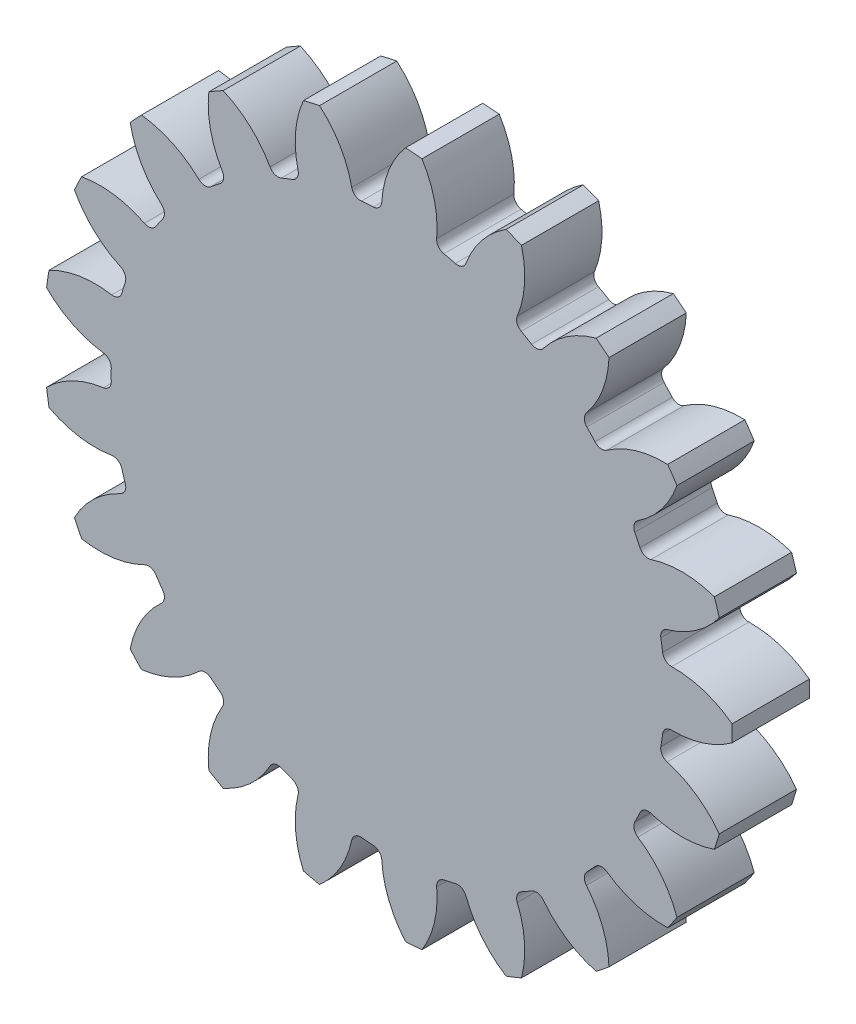
from build123d import *

# Parameters (mm, degrees)
SKETCH1_R                = 35.65
BOSS_EXTRUDE1_DEPTH      = 4
CUT_EXTRUDE1_DEPTH       = 5
FILLET1_R                = 0.93
CIRPATTERN1_COUNT        = 21
FILLET1_OF_CIRPATTERN1_R = 0.93


with BuildPart() as part:
    # Sketch1 → Boss-Extrude1 (new body, symmetric)
    with BuildSketch(Plane.XY):
        Circle(SKETCH1_R)
    extrude(amount=BOSS_EXTRUDE1_DEPTH, both=True)

    # Sketch4 → Cut-Extrude1 (cut, symmetric)
    with BuildSketch(Plane.XY):
        with BuildLine():
            ThreePointArc((-36.242364653, -5.451009479), (-32.872441369, -2.636648824), (-28.63673557, -1.480878422))
            ThreePointArc((-28.63673557, -1.480878422), (-28.675, 0), (-28.63673557, 1.480878422))
            ThreePointArc((-28.63673557, 1.480878422), (-32.872441369, 2.636648824), (-36.242364653, 5.451009479))
            ThreePointArc((-36.242364653, 5.451009479), (-36.65, 0), (-36.242364653, -5.451009479))
        make_face()
    cut_extrude1 = extrude(amount=CUT_EXTRUDE1_DEPTH, both=True, mode=Mode.SUBTRACT)

    # Fillet1
    fillet1_edges = [part.edges().sort_by_distance(p)[0] for p in [
        (-28.63673557, -1.480878422, 0),
        (-28.63673557, 1.480878422, 0),
    ]]
    fillet(fillet1_edges, radius=FILLET1_R)

    # CirPattern1: Cut-Extrude1 ×21 about axis
    cirpattern1_axis = Axis((0, 0, 0), (0, 0, 1))
    for i in range(1, CIRPATTERN1_COUNT):
        add(cut_extrude1.rotate(cirpattern1_axis, i * 360 / CIRPATTERN1_COUNT), mode=Mode.SUBTRACT)

    # Fillet1 of CirPattern1
    fillet1_of_cirpattern1_edges = [part.edges().sort_by_distance(p)[0] for p in [
        (-26.927989179, -9.855913136, 0),
        (-27.800982335, -7.025738839, 0),
        (-22.826572779, -17.355206716, 0),
        (-24.494989816, -14.908088372, 0),
        (-16.696915214, -23.312414018, 0),
        (-19.012509958, -21.46578883, 0),
        (-9.08366346, -27.198211029, 0),
        (-11.840685156, -26.116159749, 0),
        (-0.663288343, -28.667327632, 0),
        (-3.616763515, -28.445995266, 0),
        (7.816022853, -27.589226371, 0),
        (4.928523436, -28.24827927, 0),
        (15.600846118, -24.059701274, 0),
        (13.035889451, -25.540579696, 0),
        (21.999465743, -18.392366134, 0),
        (19.984959482, -20.563487533, 0),
        (26.443336294, -11.09078855, 0),
        (25.15827816, -13.759239261, 0),
        (28.53760037, -2.803745732, 0),
        (28.096173418, -5.732422199, 0),
        (28.096173418, 5.732422199, 0),
        (28.53760037, 2.803745732, 0),
        (25.15827816, 13.759239261, 0),
        (26.443336294, 11.09078855, 0),
        (19.984959482, 20.563487533, 0),
        (21.999465743, 18.392366134, 0),
        (13.035889451, 25.540579696, 0),
        (15.600846118, 24.059701274, 0),
        (4.928523436, 28.24827927, 0),
        (7.816022853, 27.589226371, 0),
        (-3.616763515, 28.445995266, 0),
        (-0.663288343, 28.667327632, 0),
        (-11.840685156, 26.116159749, 0),
        (-9.08366346, 27.198211029, 0),
        (-19.012509958, 21.46578883, 0),
        (-16.696915214, 23.312414018, 0),
        (-24.494989816, 14.908088372, 0),
        (-22.826572779, 17.355206716, 0),
        (-27.800982335, 7.025738839, 0),
        (-26.927989179, 9.855913136, 0),
    ]]
    fillet(fillet1_of_cirpattern1_edges, radius=FILLET1_OF_CIRPATTERN1_R)


solid = part.part
